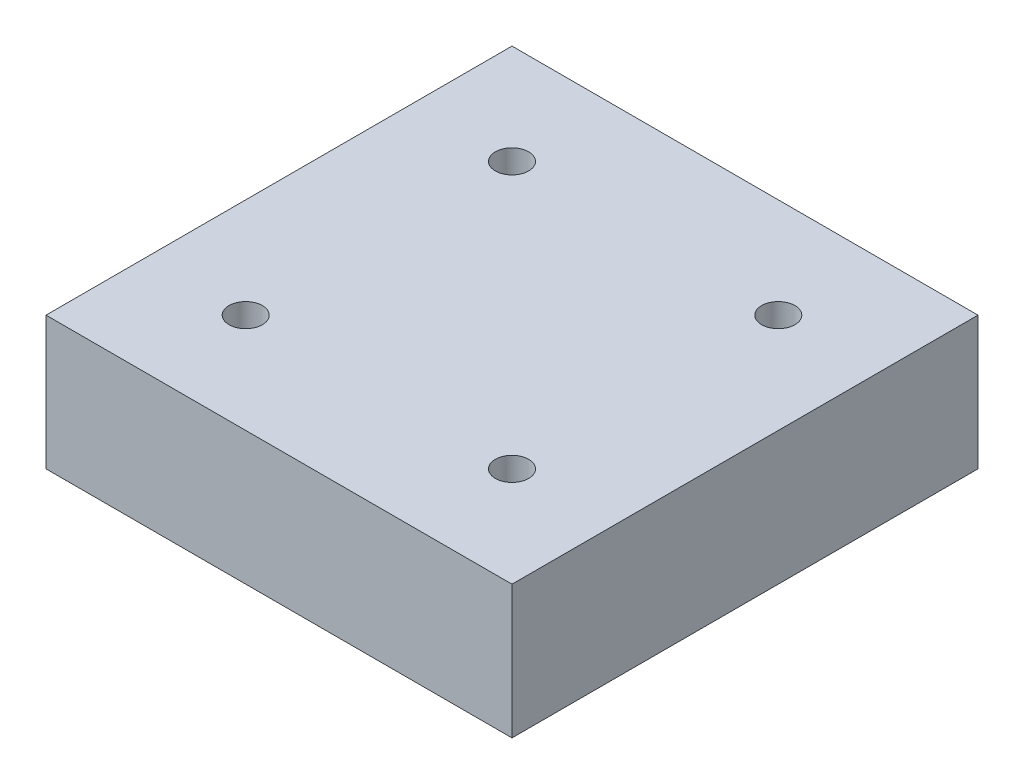
from build123d import *

# Parameters (mm, degrees)
SKETCH1_W             = 70
SKETCH1_H             = 70
BOSS_EXTRUDE1_DEPTH   = 20
M6_TAPPED_HOLE1_D     = 5
M6_TAPPED_HOLE1_DEPTH = 15
M6_TAPPED_HOLE1_TIP   = 1.502151548


with BuildPart() as part:
    # Sketch1 → Boss-Extrude1 (new body)
    with BuildSketch(Plane(origin=(0, 0, 0), x_dir=(1, 0, 0), z_dir=(0, 1, 0))):
        Rectangle(SKETCH1_W, SKETCH1_H)
    extrude(amount=BOSS_EXTRUDE1_DEPTH)

    # M6 Tapped Hole1
    with Locations(Plane(origin=(0, 20, 0), x_dir=(1, 0, 0), z_dir=(0, 1, 0))):
        with Locations((20, 20), (20, -20), (-20, -20), (-20, 20)):
            Hole(M6_TAPPED_HOLE1_D / 2, depth=M6_TAPPED_HOLE1_DEPTH)
            with Locations((0, 0, -(M6_TAPPED_HOLE1_DEPTH + M6_TAPPED_HOLE1_TIP / 2))):  # 118° drill point
                Cone(0, M6_TAPPED_HOLE1_D / 2, M6_TAPPED_HOLE1_TIP, mode=Mode.SUBTRACT)


solid = part.part
